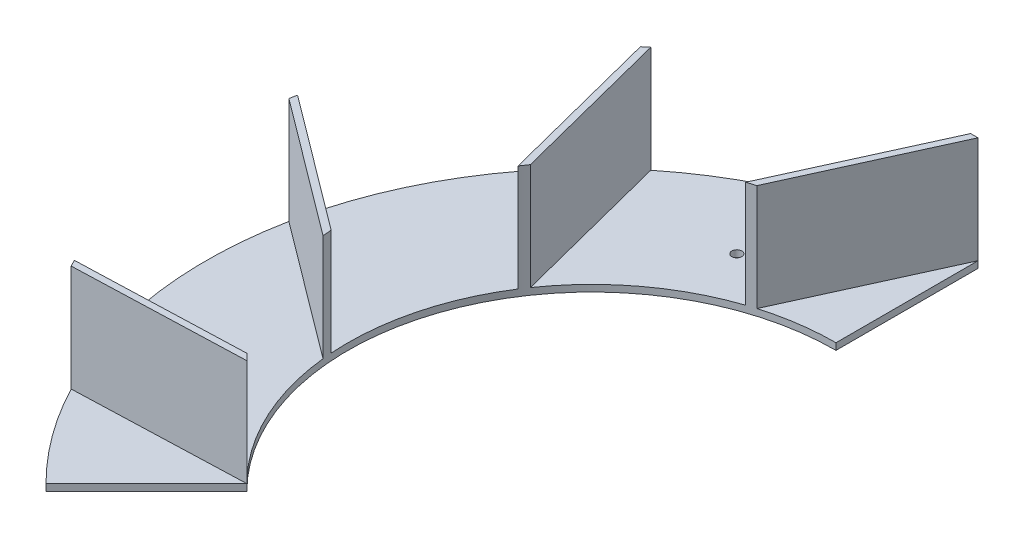
from build123d import *

# Parameters (mm, degrees)
BOSS_EXTRUDE3_DEPTH = 3
BOSS_EXTRUDE4_DEPTH = 48
CUT_EXTRUDE1_REACH  = 53
SKETCH3_R           = 2.25


with BuildPart() as part:
    # Sketch1 → Boss-Extrude3 (new body)
    with BuildSketch(Plane(origin=(0, 0, 0), x_dir=(1, 0, 0), z_dir=(0, 1, 0))):
        with BuildLine():
            Line((0, 110), (0, 174))
            ThreePointArc((0, 174), (-160.755038657, 66.586917232), (-123.036579926, -123.036579926))
            Line((-123.036579926, -123.036579926), (-77.781745931, -77.781745931))
            ThreePointArc((-77.781745931, -77.781745931), (-101.626748576, 42.09517756), (0, 110))
        make_face()
    extrude(amount=BOSS_EXTRUDE3_DEPTH)

    # Sketch2 → Boss-Extrude4 (add)
    with BuildSketch(Plane(origin=(0, 3, 0), x_dir=(1, 0, 0), z_dir=(0, 1, 0))):
        with BuildLine():
            Line((0, 174), (-31.15408253, 105.496081168))
            ThreePointArc((-31.15408253, 105.496081168), (-33.083376151, 104.907055161), (-35.001544118, 104.282749817))
            Line((-35.001544118, 104.282749817), (-3.30998401, 173.96851441))
            ThreePointArc((-3.30998401, 173.96851441), (-1.655066878, 173.992128424), (0, 174))
        make_face()
        with BuildLine():
            Line((-109.065465459, 135.575529666), (-90.400634695, 62.671566494))
            ThreePointArc((-90.400634695, 62.671566494), (-91.534672677, 61.00330891), (-92.637928339, 59.31453644))
            Line((-92.637928339, 59.31453644), (-111.624769164, 133.476255975))
            ThreePointArc((-111.624769164, 133.476255975), (-110.350109434, 134.531978904), (-109.065465459, 135.575529666))
        make_face()
        with BuildLine():
            Line((-169.961014343, 37.272692462), (-109.720790239, -7.832508497))
            ThreePointArc((-109.720790239, -7.832508497), (-109.558712711, -9.843194048), (-109.359791534, -11.850569418))
            Line((-109.359791534, -11.850569418), (-170.639294189, 34.032797103))
            ThreePointArc((-170.639294189, 34.032797103), (-170.307858813, 35.654357748), (-169.961014343, 37.272692462))
        make_face()
        with BuildLine():
            Line((-155.791483302, -77.492023659), (-80.581598087, -74.877273253))
            ThreePointArc((-80.581598087, -74.877273253), (-79.194988304, -76.342346228), (-77.781745931, -77.781745931))
            Line((-77.781745931, -77.781745931), (-154.289169819, -80.441606627))
            ThreePointArc((-154.289169819, -80.441606627), (-155.047340737, -78.970387679), (-155.791483302, -77.492023659))
        make_face()
    extrude(amount=BOSS_EXTRUDE4_DEPTH)

    # Sketch3 → Cut-Extrude1 (cut, up to next)
    with BuildSketch(Plane.XZ, mode=Mode.PRIVATE) as cut_extrude1_sk1:
        with Locations((-57.053465335, -122.35155125)):
            Circle(SKETCH3_R)
    cut_extrude1_tool1 = extrude(cut_extrude1_sk1.sketch, amount=-CUT_EXTRUDE1_REACH, mode=Mode.PRIVATE) & part.part
    add(cut_extrude1_tool1.solids().sort_by_distance((-57.053465, 0, -122.351551))[0], mode=Mode.SUBTRACT)
    # Sketch3 → Cut-Extrude1 (cut, up to next)
    with BuildSketch(Plane.XZ, mode=Mode.PRIVATE) as cut_extrude1_sk2:
        with Locations((-130.399986549, 34.940571089)):
            Circle(SKETCH3_R)
    cut_extrude1_tool2 = extrude(cut_extrude1_sk2.sketch, amount=-CUT_EXTRUDE1_REACH, mode=Mode.PRIVATE) & part.part
    add(cut_extrude1_tool2.solids().sort_by_distance((-130.399987, 0, 34.940571))[0], mode=Mode.SUBTRACT)


solid = part.part
